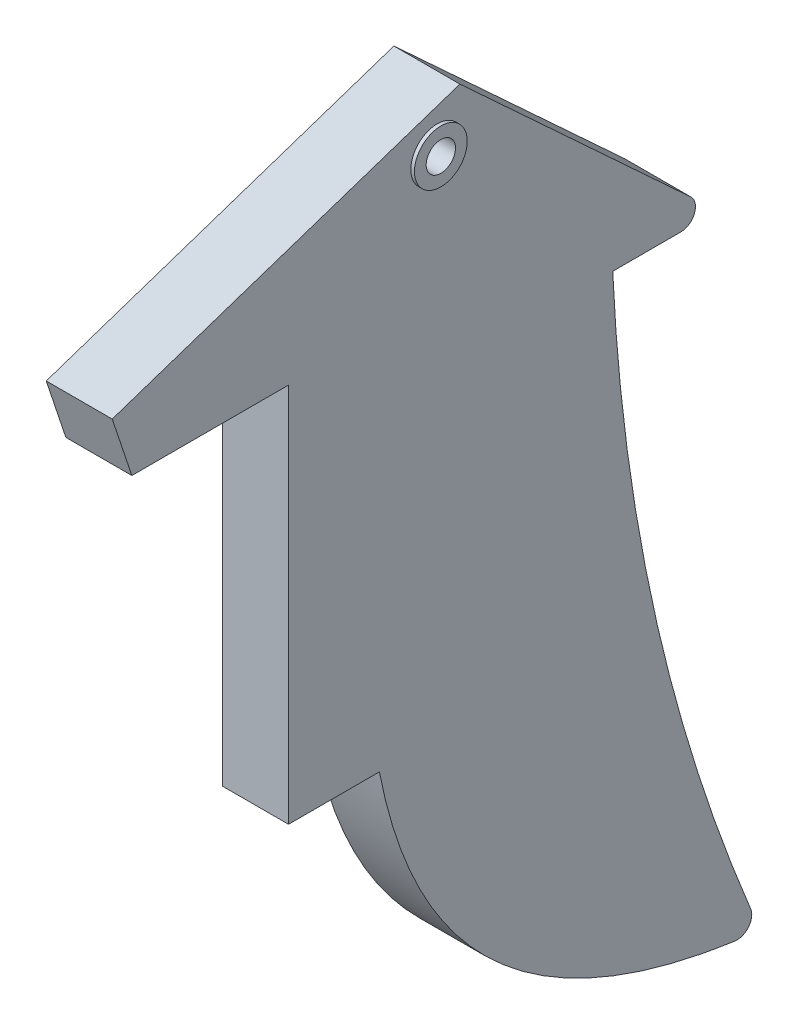
from build123d import *

# Parameters (mm, degrees)
BOSS_EXTRUDE2_DEPTH     = 4.5
SKETCH4_R               = 1
CUT_EXTRUDE2_DEPTH      = 1.0000001
CUT_EXTRUDE2_DEPTH_BACK = 5.5000001
FILLET1_R               = 1
FILLET2_R               = 1
SKETCH5_R               = 1.8
BOSS_EXTRUDE3_DEPTH     = 0.25
SKETCH7_R               = 1
CUT_EXTRUDE3_DEPTH      = 5.7500001


with BuildPart() as part:
    # Sketch3 → Boss-Extrude2 (new body)
    with BuildSketch(Plane(origin=(0, 0, 0), x_dir=(0, 0, -1), z_dir=(1, 0, 0))):
        with BuildLine():
            Line((0, 0), (-23.709832228, -7.927411666))
            Line((-23.709832228, -7.927411666), (-22.370761505, -11.93239381))
            Line((-22.370761505, -11.93239381), (-11.685771853, -11.93239381))
            Line((-11.685771853, -11.93239381), (-11.685771853, -37.874021232))
            Line((-11.685771853, -37.874021232), (-5.488568376, -37.874021232))
            add(Edge.make_bspline(
                [(-5.488568376, -37.874021232), (-1.643222614, -57.890316076), (20.496609615, -60.199338536)],
                knots=[0, 0, 0, 1, 1, 1], degree=2))
            add(Edge.make_bspline(
                [(20.496609615, -60.199338536), (11.480964524, -39.196951523), (10.423170282, -16.267555055)],
                knots=[0, 0, 0, 1, 1, 1], degree=2))
            Line((10.423170282, -16.267555055), (17.625325674, -16.267555055))
            Line((17.625325674, -16.267555055), (0, 0))
        make_face()
    extrude(amount=BOSS_EXTRUDE2_DEPTH)

    # Sketch4 → Cut-Extrude2 (cut, two sides)
    with BuildSketch(Plane(origin=(4.5, 0, 0), x_dir=(0, 0, -1), z_dir=(1, 0, 0))) as cut_extrude2_sk:
        with Locations((-1.549252561, -3.372235527)):
            Circle(SKETCH4_R)
    extrude(amount=CUT_EXTRUDE2_DEPTH, mode=Mode.SUBTRACT)
    extrude(cut_extrude2_sk.sketch, amount=-CUT_EXTRUDE2_DEPTH_BACK, mode=Mode.SUBTRACT)

    # Fillet1
    fillet1_edges = [part.edges().sort_by_distance(p)[0] for p in [
        (2.25, -16.267555055, -17.625325674),
    ]]
    fillet(fillet1_edges, radius=FILLET1_R)

    # Fillet2
    fillet2_edges = [part.edges().sort_by_distance(p)[0] for p in [
        (2.25, -60.199338536, -20.496609615),
    ]]
    fillet(fillet2_edges, radius=FILLET2_R)

    # Sketch5 → Boss-Extrude3 (add)
    with BuildSketch(Plane(origin=(4.5, 0, 0), x_dir=(0, 0, -1), z_dir=(1, 0, 0))):
        with Locations((-1.549252561, -3.372235527)):
            Circle(SKETCH5_R)
    boss_extrude3 = extrude(amount=BOSS_EXTRUDE3_DEPTH)

    # Sketch7 → Cut-Extrude3 (cut, through all)
    with BuildSketch(Plane(origin=(4.75, 0, 0), x_dir=(0, 0, -1), z_dir=(1, 0, 0))):
        with Locations((-1.549252561, -3.372235527)):
            Circle(SKETCH7_R)
    cut_extrude3 = extrude(amount=-CUT_EXTRUDE3_DEPTH, mode=Mode.SUBTRACT)

    # Mirror1: Boss-Extrude3, Cut-Extrude3 across plane
    add(boss_extrude3.mirror(Plane(origin=(2.25, 0, 0), x_dir=(0, 0, 1), z_dir=(1, 0, 0))))
    add(cut_extrude3.mirror(Plane(origin=(2.25, 0, 0), x_dir=(0, 0, 1), z_dir=(1, 0, 0))), mode=Mode.SUBTRACT)


solid = part.part
